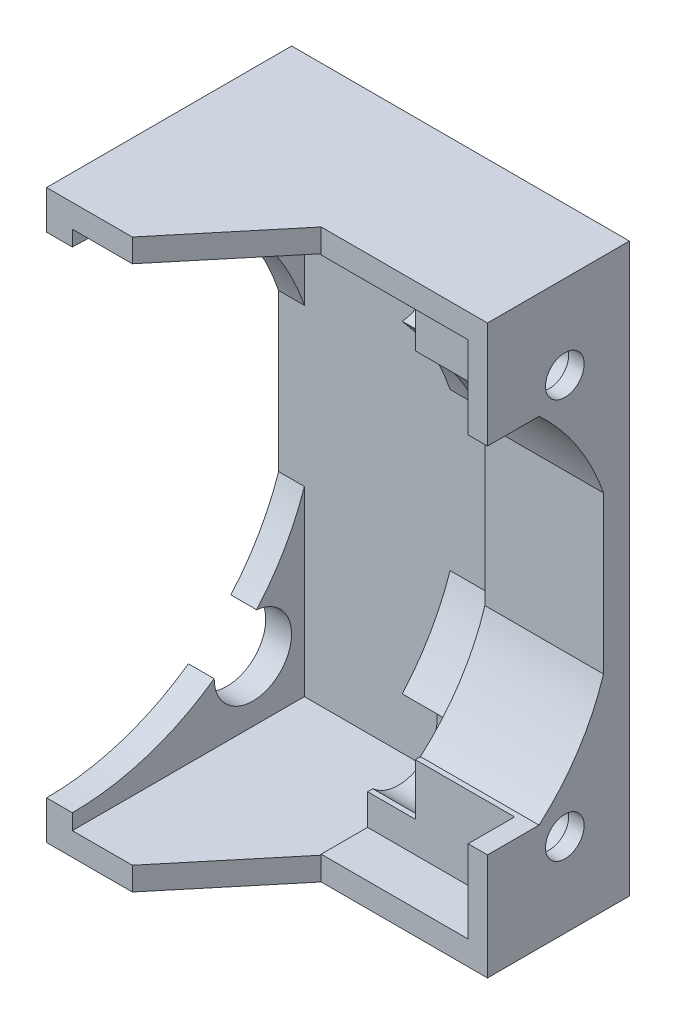
from build123d import *

# Parameters (mm, degrees)
CROQUIS1_W               = 25
CROQUIS1_H               = 44
SALIENTE_EXTRUIR1_DEPTH  = 20
CROQUIS2_W               = 11.3
CROQUIS2_H               = 40.4
CORTAR_EXTRUIR1_DEPTH    = 18
CROQUIS3_W               = 10.7
CROQUIS3_H               = 44
CORTAR_EXTRUIR2_DEPTH    = 12
CORTAR_EXTRUIR3_START    = -25
CROQUIS4_R               = 1.6
CORTAR_EXTRUIR3_DEPTH    = 25
CROQUIS5_R               = 3
CORTAR_EXTRUIR4_DEPTH    = 17
CROQUIS7_W               = 10.7
CROQUIS7_H               = 2.131966011
SALIENTE_EXTRUIR2_DEPTH  = 12
CROQUIS9_W               = 11.3
CROQUIS9_H               = 12.16552506
SALIENTE_EXTRUIR3_DEPTH  = 2
SALIENTE_EXTRUIR4_DEPTH  = 2
CORTAR_EXTRUIR10_START   = -25
CROQUIS12_W              = 0.99
CROQUIS12_H              = 44
CORTAR_EXTRUIR10_DEPTH   = 25
CROQUIS13_W              = 8
CROQUIS13_H              = 44
CORTAR_EXTRUIR11_DEPTH   = 11.7
SALIENTE_EXTRUIR5_DEPTH  = 11.7
CROQUIS15_W              = 10.763613753
CROQUIS15_H              = 40.736067978
CORTAR_EXTRUIR12_DEPTH   = 4
CROQUIS16_R              = 1.5
SALIENTE_EXTRUIR6_DEPTH  = 1.2
CORTAR_EXTRUIR13_START   = -44
CORTAR_EXTRUIR13_DEPTH   = 44
CROQUIS18_W              = 0.936386247
CROQUIS18_H              = 40.568033989
CORTAR_EXTRUIR14_DEPTH   = 4
SALIENTE_EXTRUIR7_START  = -9.2
SALIENTE_EXTRUIR7_DEPTH  = 9.2
SALIENTE_EXTRUIR8_START  = -12.9
CROQUIS20_W              = 4
CROQUIS20_H              = 0.236067978
CROQUIS20_H_2            = 0.25
SALIENTE_EXTRUIR8_DEPTH  = 12.9
CROQUIS21_W              = 4
CROQUIS21_H              = 6.401046148
CROQUIS21_H_2            = 6.387114126
SALIENTE_EXTRUIR9_DEPTH  = 1.5
SALIENTE_EXTRUIR10_DEPTH = 0.4


with BuildPart() as part:
    # Croquis1 → Saliente-Extruir1 (new body)
    with BuildSketch(Plane.XY):
        with Locations((-22.114132301, -13.090425532)):
            Rectangle(CROQUIS1_W, CROQUIS1_H)
    extrude(amount=SALIENTE_EXTRUIR1_DEPTH)

    # Croquis2 → Cortar-Extruir1 (cut)
    with BuildSketch(Plane.XY.offset(20)):
        with Locations((-26.964132301, -13.090425532)):
            Rectangle(CROQUIS2_W, CROQUIS2_H)
    extrude(amount=-CORTAR_EXTRUIR1_DEPTH, mode=Mode.SUBTRACT)

    # Croquis3 → Cortar-Extruir2 (cut)
    with BuildSketch(Plane.XY.offset(20)):
        with Locations((-14.964132301, -13.090425532)):
            Rectangle(CROQUIS3_W, CROQUIS3_H)
    extrude(amount=-CORTAR_EXTRUIR2_DEPTH, mode=Mode.SUBTRACT)

    # Croquis4 → Cortar-Extruir3 (cut)
    with BuildSketch(Plane.ZY.offset(34.614132301).offset(CORTAR_EXTRUIR3_START)):
        with Locations((6, 2.409574468)):
            Circle(CROQUIS4_R)
        with Locations((6, -28.590425532)):
            Circle(CROQUIS4_R)
        with BuildLine():
            Line((20, 5.909574468), (20, -32.090425532))
            ThreePointArc((20, -32.090425532), (1, -13.090425532), (20, 5.909574468))
        make_face()
    extrude(amount=CORTAR_EXTRUIR3_DEPTH, mode=Mode.SUBTRACT)

    # Croquis5 → Cortar-Extruir4 (cut)
    with BuildSketch(Plane.ZY.offset(34.614132301)):
        with Locations((6, 2.409574468)):
            Circle(CROQUIS5_R)
        with Locations((6, -28.590425532)):
            Circle(CROQUIS5_R)
    extrude(amount=-CORTAR_EXTRUIR4_DEPTH, mode=Mode.SUBTRACT)

    # Croquis7 → Saliente-Extruir2 (add)
    with BuildSketch(Plane.XY.offset(8)):
        with Locations((-14.964132301, -34.024442527)):
            Rectangle(CROQUIS7_W, CROQUIS7_H)
        with Locations((-14.964132301, 7.843591463)):
            Rectangle(CROQUIS7_W, CROQUIS7_H)
    extrude(amount=SALIENTE_EXTRUIR2_DEPTH)

    # Croquis9 → Saliente-Extruir3 (add)
    with BuildSketch(Plane.XY.offset(2)):
        with Locations((-26.964132301, -13.090425532)):
            Rectangle(CROQUIS9_W, CROQUIS9_H)
    extrude(amount=-SALIENTE_EXTRUIR3_DEPTH)

    # Croquis11 → Saliente-Extruir4 (add)
    with BuildSketch(Plane.ZY.offset(32.614132301)):
        with BuildLine():
            Line((2, -7.007663002), (2, -19.173188062))
            ThreePointArc((2, -19.173188062), (1, -13.090425532), (2, -7.007663002))
        make_face()
    extrude(amount=SALIENTE_EXTRUIR4_DEPTH)

    # Croquis12 → Cortar-Extruir10 (cut)
    with BuildSketch(Plane.ZY.offset(34.614132301).offset(CORTAR_EXTRUIR10_START)):
        with Locations((0.495, -13.090425532)):
            Rectangle(CROQUIS12_W, CROQUIS12_H)
    extrude(amount=CORTAR_EXTRUIR10_DEPTH, mode=Mode.SUBTRACT)

    # Croquis13 → Cortar-Extruir11 (cut)
    with BuildSketch(Plane(origin=(-9.614132301, 0, 0), x_dir=(0, 0, -1), z_dir=(1, 0, 0))):
        with Locations((-16, -13.090425532)):
            Rectangle(CROQUIS13_W, CROQUIS13_H)
    extrude(amount=-CORTAR_EXTRUIR11_DEPTH, mode=Mode.SUBTRACT)

    # Croquis14 → Saliente-Extruir5 (add)
    with BuildSketch(Plane(origin=(-21.314132301, 0, 0), x_dir=(0, 0, -1), z_dir=(1, 0, 0))):
        with BuildLine():
            Line((-2, -19.173188062), (-2, -7.007663002))
            ThreePointArc((-2, -7.007663002), (-1, -13.090425532), (-2, -19.173188062))
        make_face()
    extrude(amount=SALIENTE_EXTRUIR5_DEPTH)

    # Croquis15 → Cortar-Extruir12 (cut)
    with BuildSketch(Plane.XY.offset(12)):
        with Locations((-14.995939178, -13.090425532)):
            Rectangle(CROQUIS15_W, CROQUIS15_H)
    extrude(amount=-CORTAR_EXTRUIR12_DEPTH, mode=Mode.SUBTRACT)

    # Croquis16 → Saliente-Extruir6 (add)
    with BuildSketch(Plane(origin=(-9.614132301, 0, 0), x_dir=(0, 0, -1), z_dir=(1, 0, 0))):
        with BuildLine():
            Line((-8, -27.821345395), (-8, -33.458459521))
            Line((-8, -33.458459521), (-12, -33.458459521))
            Line((-12, -33.458459521), (-12, -35.090425532))
            Line((-12, -35.090425532), (-0.99, -35.090425532))
            Line((-0.99, -35.090425532), (-0.99, 8.909574468))
            Line((-0.99, 8.909574468), (-12, 8.909574468))
            Line((-12, 8.909574468), (-12, 7.277608457))
            Line((-12, 7.277608457), (-8, 7.277608457))
            Line((-8, 7.277608457), (-8, 1.640494331))
            ThreePointArc((-8, 1.640494331), (-4.389181434, -2.259804881), (-2, -7.007663002))
            Line((-2, -7.007663002), (-2, -19.173188062))
            ThreePointArc((-2, -19.173188062), (-4.389181434, -23.921046183), (-8, -27.821345395))
        make_face()
        with Locations((-6, -28.590425532)):
            Circle(CROQUIS16_R, mode=Mode.SUBTRACT)
        with Locations((-6, 2.409574468)):
            Circle(CROQUIS16_R, mode=Mode.SUBTRACT)
    extrude(amount=SALIENTE_EXTRUIR6_DEPTH)

    # Croquis17 → Cortar-Extruir13 (cut)
    with BuildSketch(Plane.XZ.offset(35.090425532).offset(CORTAR_EXTRUIR13_START)):
        Polygon((-21.314132301, 12), (-21.314132301, 20), (-27.964132301, 20), align=None)
    extrude(amount=CORTAR_EXTRUIR13_DEPTH, mode=Mode.SUBTRACT)

    # Croquis18 → Cortar-Extruir14 (cut)
    with BuildSketch(Plane.XY.offset(12)):
        with Locations((-20.845939178, -13.006408538)):
            Rectangle(CROQUIS18_W, CROQUIS18_H)
    extrude(amount=-CORTAR_EXTRUIR14_DEPTH, mode=Mode.SUBTRACT)

    # Croquis19 → Saliente-Extruir7 (add)
    with BuildSketch(Plane(origin=(-8.414132301, 0, 0), x_dir=(0, 0, -1), z_dir=(1, 0, 0)).offset(SALIENTE_EXTRUIR7_START)):
        with BuildLine():
            Line((-2, -19.173188062), (-2, -7.007663002))
            ThreePointArc((-2, -7.007663002), (-4.389181434, -2.259804881), (-8, 1.640494331))
            Line((-8, 1.640494331), (-8, 0.640494331))
            ThreePointArc((-8, 0.640494331), (-5.026875227, -2.874277954), (-3, -7.007663002))
            Line((-3, -7.007663002), (-3, -19.173188062))
            ThreePointArc((-3, -19.173188062), (-4.972698099, -23.341991528), (-8, -26.821345395))
            Line((-8, -26.821345395), (-8, -27.821345395))
            ThreePointArc((-8, -27.821345395), (-4.389181434, -23.921046183), (-2, -19.173188062))
        make_face()
    extrude(amount=SALIENTE_EXTRUIR7_DEPTH)

    # Croquis20 → Saliente-Extruir8 (add)
    with BuildSketch(Plane(origin=(-8.414132301, 0, 0), x_dir=(0, 0, -1), z_dir=(1, 0, 0)).offset(SALIENTE_EXTRUIR8_START)):
        with Locations((-10, -33.340425532)):
            Rectangle(CROQUIS20_W, CROQUIS20_H)
        with Locations((-10, 7.152608457)):
            Rectangle(CROQUIS20_W, CROQUIS20_H_2)
    extrude(amount=SALIENTE_EXTRUIR8_DEPTH)

    # Croquis21 → Saliente-Extruir9 (add)
    with BuildSketch(Plane(origin=(-8.414132301, 0, 0), x_dir=(0, 0, -1), z_dir=(1, 0, 0))):
        with Locations((-10, -30.021868469)):
            Rectangle(CROQUIS21_W, CROQUIS21_H)
        with Locations((-10, 3.834051394)):
            Rectangle(CROQUIS21_W, CROQUIS21_H_2)
    extrude(amount=-SALIENTE_EXTRUIR9_DEPTH)

    # Croquis22 → Saliente-Extruir10 (add)
    with BuildSketch(Plane.XY.offset(8)):
        Polygon((-9.914132301, 7.027608457), (-21.314132301, 7.027608457), (-21.314132301, 4.645642446), (-17.614132301, 4.645642446), (-17.614132301, 0.640494331), (-9.914132301, 0.640494331), align=None)
        Polygon((-9.914132301, -26.821345395), (-17.614132301, -26.821345395), (-17.614132301, -30.826493509), (-21.314132301, -30.826493509), (-21.314132301, -33.222391543), (-9.914132301, -33.222391543), align=None)
    extrude(amount=SALIENTE_EXTRUIR10_DEPTH)


solid = part.part
